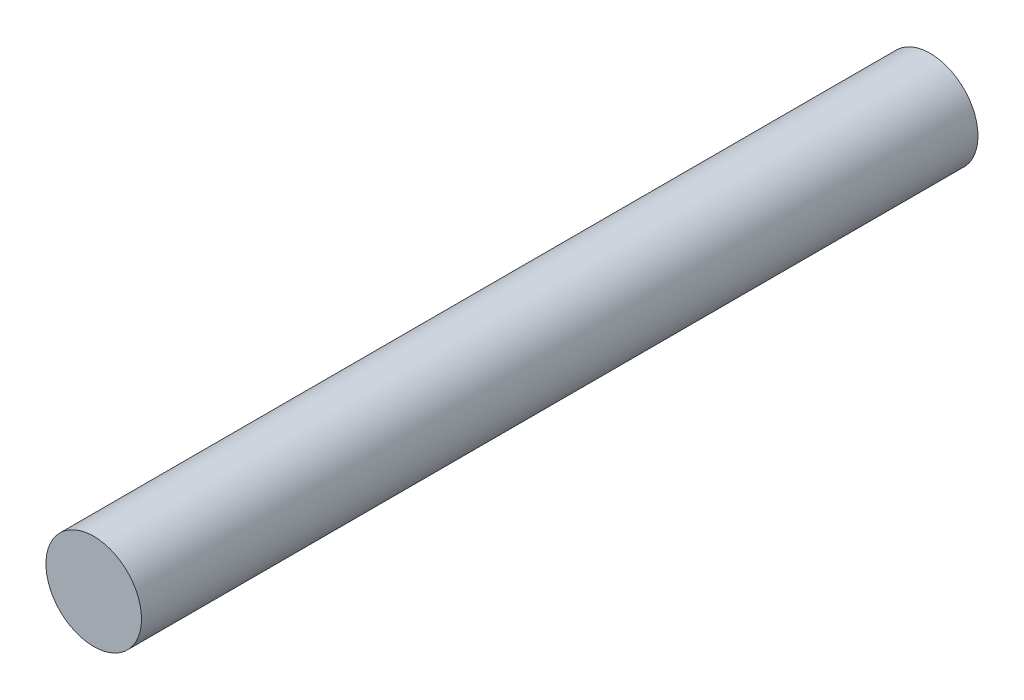
from build123d import *

# Parameters (mm, degrees)
ESQUISSE1_R        = 4
BOSS_EXTRU_1_DEPTH = 70


with BuildPart() as part:
    # Esquisse1 → Boss.-Extru.1 (new body)
    with BuildSketch(Plane.XY):
        with Locations((280, 0)):
            Circle(ESQUISSE1_R)
    extrude(amount=BOSS_EXTRU_1_DEPTH)


solid = part.part
